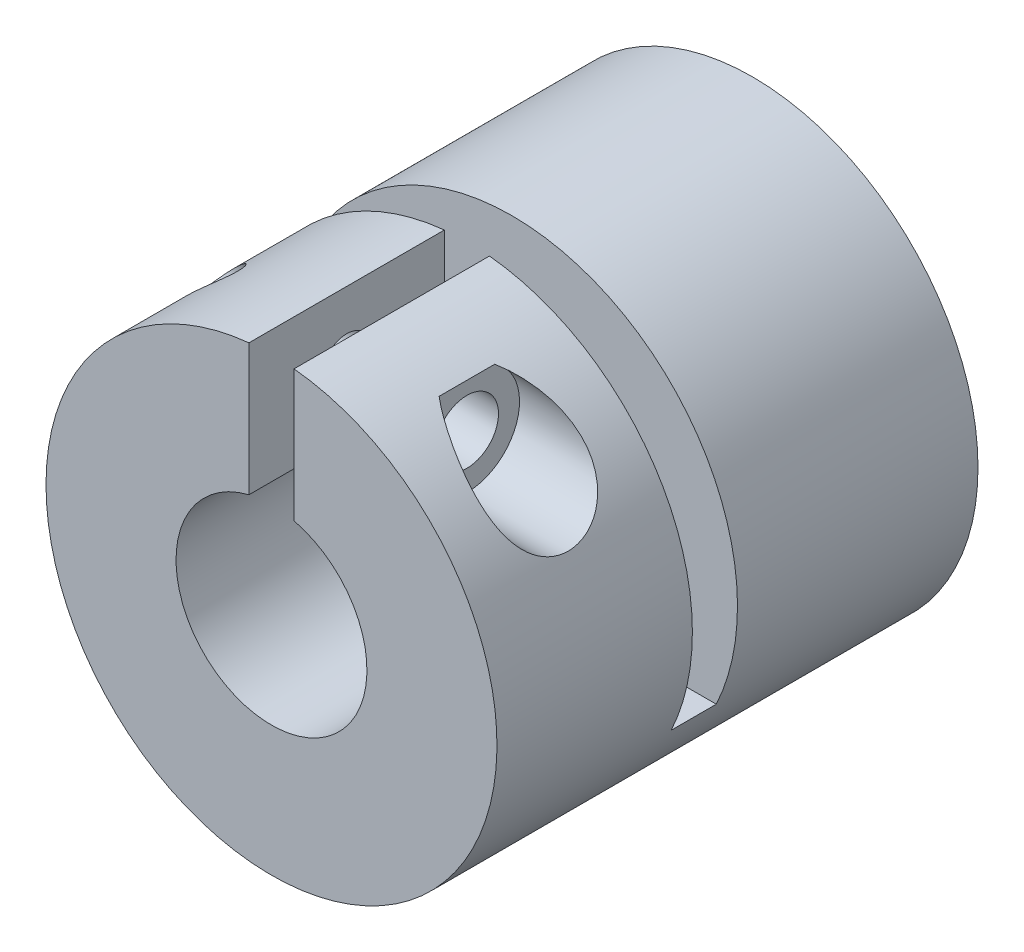
from build123d import *

# Parameters (mm, degrees)
SKETCH1_R               = 15
SKETCH1_R_2             = 6.35
BOSS_EXTRUDE1_DEPTH     = 32
CUT_EXTRUDE1_DEPTH      = 16
CUT_EXTRUDE2_START      = -21.35
SKETCH3_W               = 30
SKETCH3_H               = 3
CUT_EXTRUDE2_DEPTH      = 21.274812
SKETCH4_R               = 1.65
CUT_EXTRUDE3_DEPTH      = 17.5
CUT_EXTRUDE3_DEPTH_BACK = 14.5
SKETCH5_R               = 2.1
CUT_EXTRUDE4_DEPTH      = 14.5000001
SKETCH6_R               = 3.5
CUT_EXTRUDE5_DEPTH      = 8.5


with BuildPart() as part:
    # Sketch1 → Boss-Extrude1 (new body)
    with BuildSketch(Plane.XY):
        Circle(SKETCH1_R)
        Circle(SKETCH1_R_2, mode=Mode.SUBTRACT)
    extrude(amount=BOSS_EXTRUDE1_DEPTH)

    # Sketch2 → Cut-Extrude1 (cut)
    with BuildSketch(Plane.XY.offset(32)):
        with BuildLine():
            Line((-1.5, 6.170291727), (-1.5, 14.924811557))
            ThreePointArc((-1.5, 14.924811557), (0, 16.424811557), (1.5, 14.924811557))
            Line((1.5, 14.924811557), (1.5, 6.170291727))
            ThreePointArc((1.5, 6.170291727), (0, 4.670291727), (-1.5, 6.170291727))
        make_face()
    extrude(amount=-CUT_EXTRUDE1_DEPTH, mode=Mode.SUBTRACT)

    # Sketch3 → Cut-Extrude2 (cut)
    with BuildSketch(Plane(origin=(0, 15, 0), x_dir=(1, 0, 0), z_dir=(0, 1, 0)).offset(CUT_EXTRUDE2_START)):
        with Locations((0, -17.5)):
            Rectangle(SKETCH3_W, SKETCH3_H)
    extrude(amount=CUT_EXTRUDE2_DEPTH, mode=Mode.SUBTRACT)

    # Sketch4 → Cut-Extrude3 (cut, two sides)
    with BuildSketch(Plane(origin=(-1.5, 0, 0), x_dir=(0, 0, -1), z_dir=(1, 0, 0))) as cut_extrude3_sk:
        with Locations((-25.5, 10.547551642)):
            Circle(SKETCH4_R)
    extrude(amount=CUT_EXTRUDE3_DEPTH, mode=Mode.SUBTRACT)
    extrude(cut_extrude3_sk.sketch, amount=-CUT_EXTRUDE3_DEPTH_BACK, mode=Mode.SUBTRACT)

    # Sketch5 → Cut-Extrude4 (cut, through all)
    with BuildSketch(Plane.ZY.offset(-1.5)):
        with Locations((25.5, 10.547551642)):
            Circle(SKETCH5_R)
    extrude(amount=-CUT_EXTRUDE4_DEPTH, mode=Mode.SUBTRACT)

    # Sketch6 → Cut-Extrude5 (cut)
    with BuildSketch(Plane(origin=(15, 0, 0), x_dir=(0, 0, -1), z_dir=(1, 0, 0))):
        with Locations((-25.5, 10.547551642)):
            Circle(SKETCH6_R)
    extrude(amount=-CUT_EXTRUDE5_DEPTH, mode=Mode.SUBTRACT)


solid = part.part
